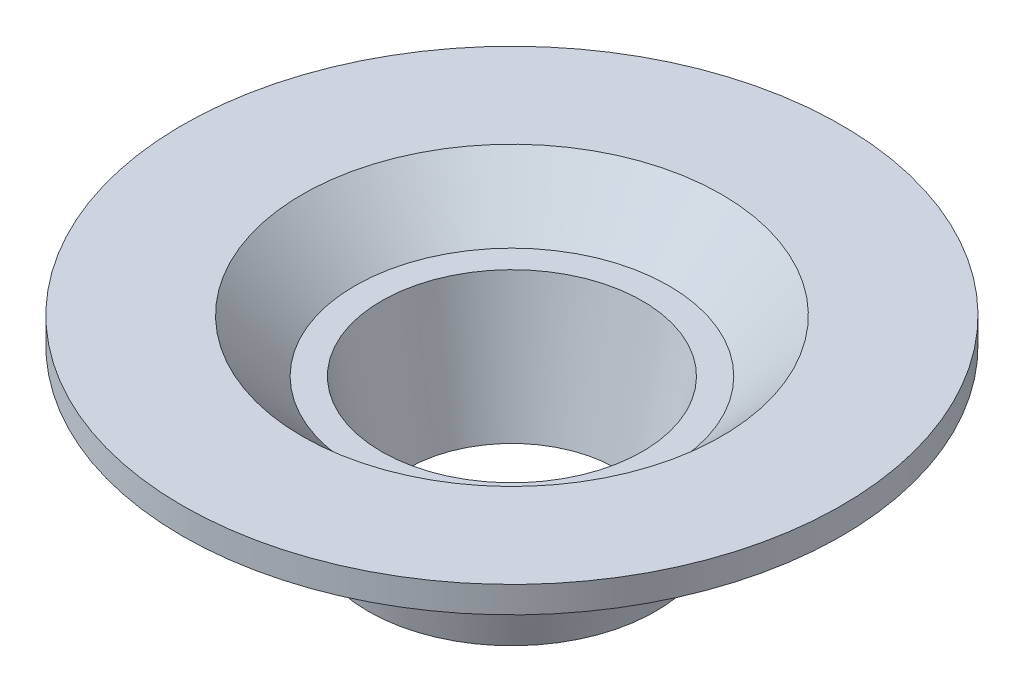
from build123d import *


with BuildPart() as part:
    # Sketch1 → Revolve1 (revolve)
    with BuildSketch(Plane.XY):
        Polygon((4.95, 0), (5.95, 0), (7.95, 2), (12.5, 2), (12.5, 1), (10.5, 1), (8.5, -1), (6.25, -1), (5.45, -5), (3.95, -5), align=None)
    revolve(axis=Axis((0, 0, 0), (0, -1, 0)))


solid = part.part
